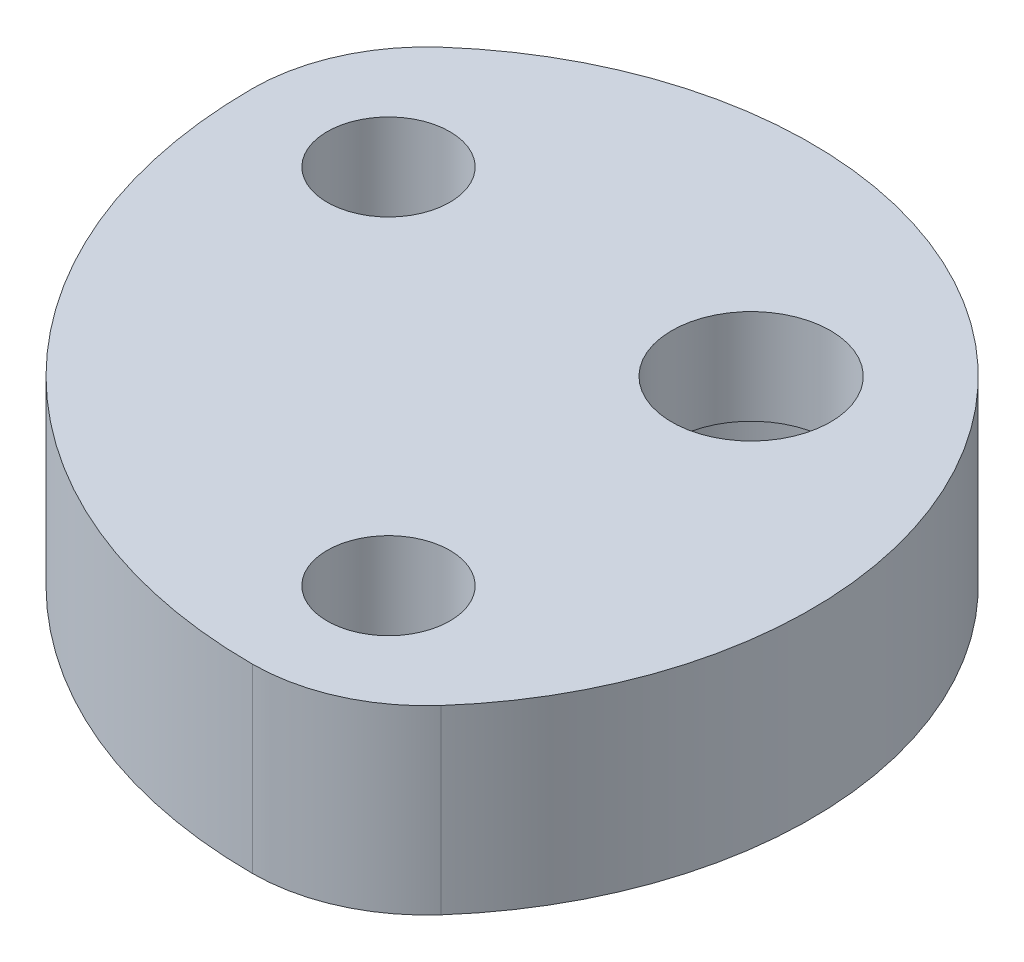
from build123d import *

# Parameters (mm, degrees)
BOSS_EXTRUDE1_DEPTH   = 4
F_6_32_TAPPED_HOLE1_D = 2.7051
SKETCH4_R             = 3.044
CUT_EXTRUDE1_DEPTH    = 1.905
SKETCH5_R             = 1.75
CUT_EXTRUDE2_DEPTH    = 16.696783906


with BuildPart() as part:
    # Sketch1 → Boss-Extrude1 (new body)
    with BuildSketch(Plane(origin=(0, 0, 0), x_dir=(1, 0, 0), z_dir=(0, 1, 0))):
        with BuildLine():
            ThreePointArc((2.505986433, 2.505986433), (5.111833916, -3.531413722), (2.866848356, -9.712083716))
            ThreePointArc((2.866848356, -9.712083716), (1.571428319, -10.663233366), (0, -11))
            ThreePointArc((0, -11), (-7.778174593, -7.778174593), (-11, 0))
            ThreePointArc((-11, 0), (-10.663233366, 1.571428319), (-9.712083716, 2.866848356))
            ThreePointArc((-9.712083716, 2.866848356), (-3.531413722, 5.111833916), (2.505986433, 2.505986433))
        make_face()
    extrude(amount=BOSS_EXTRUDE1_DEPTH)

    # 6-32 Tapped Hole1 (through all)
    with Locations(Plane(origin=(0, 0, 0), x_dir=(-1, 0, 0), z_dir=(0, -1, 0))):
        with Locations((8, 0), (0, -8)):
            Hole(F_6_32_TAPPED_HOLE1_D / 2)

    # Sketch4 → Cut-Extrude1 (cut)
    with BuildSketch(Plane.XZ):
        Circle(SKETCH4_R)
    extrude(amount=-CUT_EXTRUDE1_DEPTH, mode=Mode.SUBTRACT)

    # Sketch5 → Cut-Extrude2 (cut, through all)
    with BuildSketch(Plane.XZ.offset(-1.905)):
        Circle(SKETCH5_R)
    extrude(amount=-CUT_EXTRUDE2_DEPTH, mode=Mode.SUBTRACT)


solid = part.part
